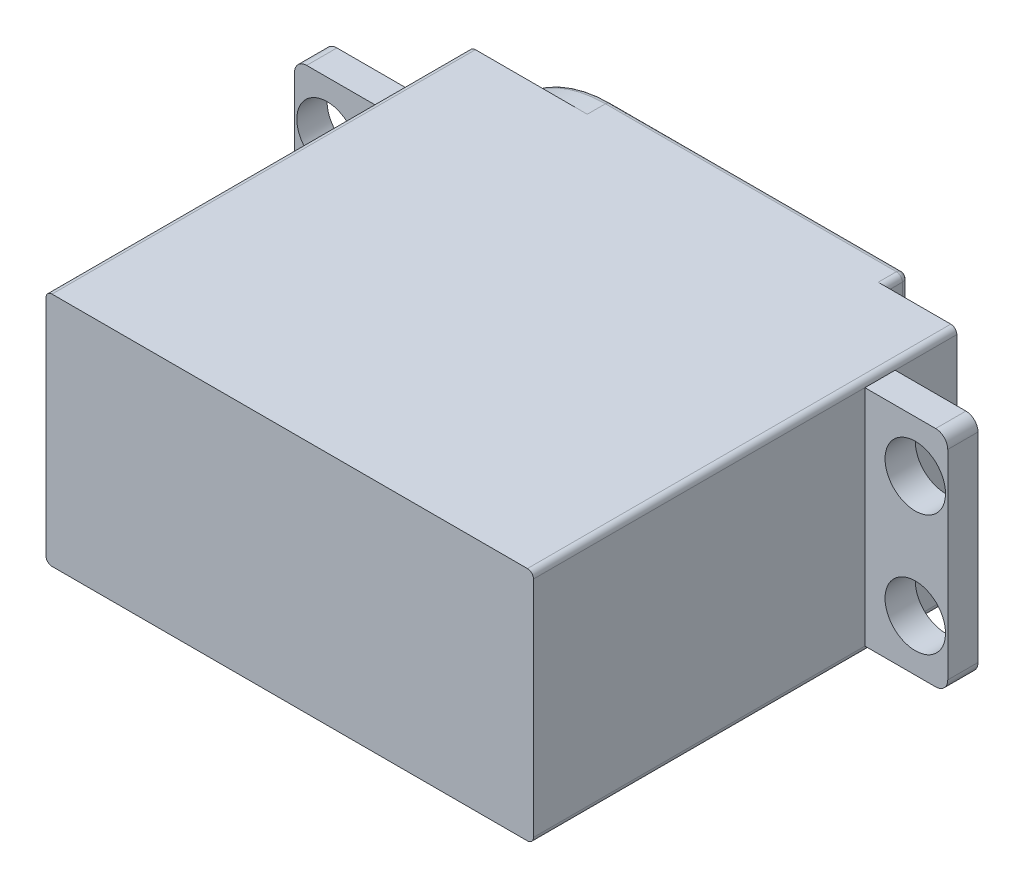
from build123d import *

# Parameters (mm, degrees)
EXTRUDE_1_DEPTH     = 35
EXTRUDE_2_DEPTH     = 2
SKETCH_10_R         = 7
EXTRUDE_6_DEPTH     = 2
SKETCH_15_R         = 2.9
EXTRUDE_7_DEPTH     = 4
SKETCH_16_R         = 1.5
CUT_EXTRUDE_1_DEPTH = 4
SKETCH_17_W         = 2.5
SKETCH_17_H         = 18.5
EXTRUDE_9_DEPTH     = 6.85
SKETCH_19_R         = 2.5
CUT_EXTRUDE_2_DEPTH = 30.9
FILLET_1_R          = 1
FILLET_2_R          = 1
FILLET_3_R          = 1
FILLET_4_R          = 1
FILLET_5_R          = 0.5
FILLET_6_R          = 0.5
FILLET_7_R          = 0.5


with BuildPart() as part:
    # 草图1 → 凸台-拉伸1 (new body)
    with BuildSketch(Plane.XY):
        with BuildLine():
            Line((-8.135874765, 0.713393676), (31.164125235, 0.713393676))
            ThreePointArc((31.164125235, 0.713393676), (31.517678626, 0.566947067), (31.664125235, 0.213393676))
            Line((31.664125235, 0.213393676), (31.664125235, -18.286606324))
            ThreePointArc((31.664125235, -18.286606324), (31.517678626, -18.640159714), (31.164125235, -18.786606324))
            Line((31.164125235, -18.786606324), (-8.135874765, -18.786606324))
            ThreePointArc((-8.135874765, -18.786606324), (-8.489428155, -18.640159714), (-8.635874765, -18.286606324))
            Line((-8.635874765, -18.286606324), (-8.635874765, 0.213393676))
            ThreePointArc((-8.635874765, 0.213393676), (-8.489428155, 0.566947067), (-8.135874765, 0.713393676))
        make_face()
    extrude(amount=EXTRUDE_1_DEPTH)

    # 草图2 → 凸台-拉伸2 (add)
    with BuildSketch(Plane(origin=(0, 0, 0), x_dir=(-1, 0, 0), z_dir=(0, 0, -1))):
        with BuildLine():
            Line((-25.664125235, -18.286606324), (-25.664125235, 0.213393676))
            ThreePointArc((-25.664125235, 0.213393676), (-25.517678626, 0.566947067), (-25.164125235, 0.713393676))
            Line((-25.164125235, 0.713393676), (-1.114125235, 0.713393676))
            ThreePointArc((-1.114125235, 0.713393676), (8.635874765, -9.036606324), (-1.114125235, -18.786606324))
            Line((-1.114125235, -18.786606324), (-25.164125235, -18.786606324))
            ThreePointArc((-25.164125235, -18.786606324), (-25.517678626, -18.640159714), (-25.664125235, -18.286606324))
        make_face()
    extrude(amount=EXTRUDE_2_DEPTH)

    # 草图10 → 凸台-拉伸6 (add)
    with BuildSketch(Plane(origin=(0, 0, -2), x_dir=(-1, 0, 0), z_dir=(0, 0, -1))):
        with Locations((-1.664125235, -9.036606324)):
            Circle(SKETCH_10_R)
    extrude(amount=EXTRUDE_6_DEPTH)

    # 草图15 → 凸台-拉伸7 (add)
    with BuildSketch(Plane(origin=(0, 0, -4), x_dir=(-1, 0, 0), z_dir=(0, 0, -1))):
        with Locations((-1.664125235, -9.036606324)):
            Circle(SKETCH_15_R)
    extrude(amount=EXTRUDE_7_DEPTH)

    # 草图16 → 切除-拉伸1 (cut)
    with BuildSketch(Plane(origin=(0, 0, -8), x_dir=(-1, 0, 0), z_dir=(0, 0, -1))):
        with Locations((-1.664125235, -9.036606324)):
            Circle(SKETCH_16_R)
    extrude(amount=-CUT_EXTRUDE_1_DEPTH, mode=Mode.SUBTRACT)

    # 草图17 → 凸台-拉伸9 (add)
    with BuildSketch(Plane(origin=(31.664125235, 0, 0), x_dir=(0, 0, -1), z_dir=(1, 0, 0))):
        with Locations((-6.35, -9.036606324)):
            Rectangle(SKETCH_17_W, SKETCH_17_H)
    extrude_9 = extrude(amount=EXTRUDE_9_DEPTH)

    # 草图19 → 切除-拉伸2 (cut, through all)
    with BuildSketch(Plane(origin=(0, 0, 5.1), x_dir=(-1, 0, 0), z_dir=(0, 0, -1))):
        with Locations((-35.829125235, -4.036606324)):
            Circle(SKETCH_19_R)
        with Locations((-35.829125235, -14.036606324)):
            Circle(SKETCH_19_R)
    cut_extrude_2 = extrude(amount=-CUT_EXTRUDE_2_DEPTH, mode=Mode.SUBTRACT)

    # 镜向3: 凸台-拉伸9, 切除-拉伸2 across plane
    add(extrude_9.mirror(Plane.ZY.offset(-11.514125235)))
    add(cut_extrude_2.mirror(Plane.ZY.offset(-11.514125235)), mode=Mode.SUBTRACT)

    # 圆角1
    fillet_1_edges = [part.edges().sort_by_distance(p)[0] for p in [
        (38.514125235, 0.213393676, 6.35),
    ]]
    fillet(fillet_1_edges, radius=FILLET_1_R)

    # 圆角2
    fillet_2_edges = [part.edges().sort_by_distance(p)[0] for p in [
        (38.514125235, -18.286606324, 6.35),
    ]]
    fillet(fillet_2_edges, radius=FILLET_2_R)

    # 圆角3
    fillet_3_edges = [part.edges().sort_by_distance(p)[0] for p in [
        (-15.485874765, 0.213393676, 6.35),
    ]]
    fillet(fillet_3_edges, radius=FILLET_3_R)

    # 圆角4
    fillet_4_edges = [part.edges().sort_by_distance(p)[0] for p in [
        (-15.485874765, -18.286606324, 6.35),
    ]]
    fillet(fillet_4_edges, radius=FILLET_4_R)

    # 圆角5
    fillet_5_edges = [part.edges().sort_by_distance(p)[0] for p in [
        (4.564125235, -9.036606324, -8),
    ]]
    fillet(fillet_5_edges, radius=FILLET_5_R)

    # 圆角6
    fillet_6_edges = [part.edges().sort_by_distance(p)[0] for p in [
        (8.664125235, -9.036606324, -4),
    ]]
    fillet(fillet_6_edges, radius=FILLET_6_R)

    # 圆角7
    fillet_7_edges = [part.edges().sort_by_distance(p)[0] for p in [
        (13.139125235, 0.713393676, -2),
        (25.664125235, -9.036606324, -2),
        (13.139125235, -18.786606324, -2),
        (-8.635874765, -9.036606324, -2),
    ]]
    fillet(fillet_7_edges, radius=FILLET_7_R)


solid = part.part
